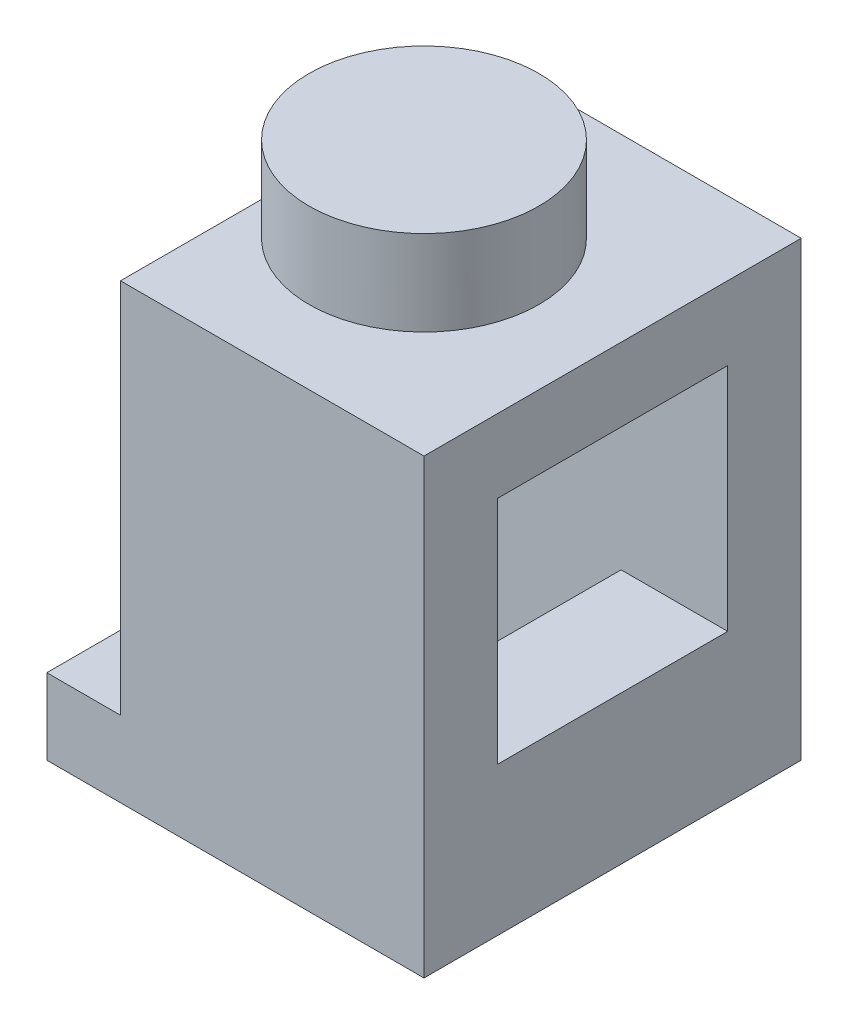
from build123d import *

# Parameters (mm, degrees)
SKETCH1_W      = 7.96
SKETCH1_H      = 7.96
EXTRUDE1_DEPTH = 9.54
SKETCH2_R      = 2.425
EXTRUDE2_DEPTH = 1.8
SHELL1_T       = -1.55
SKETCH3_W      = 4.86
SKETCH3_H      = 4.86
EXTRUDE3_DEPTH = 0.14
SKETCH5_W      = 1.555
SKETCH5_H      = 7.96
EXTRUDE5_DEPTH = 7.94
SKETCH7_W      = 0.7
SKETCH7_H      = 4.86
EXTRUDE6_DEPTH = 6.53
EXTRUDE7_REACH = 9.96
SKETCH4_W      = 4.86
SKETCH4_H      = 4.86
SKETCH8_R      = 2.425
EXTRUDE8_DEPTH = 1.555
SKETCH9_R      = 1.565
EXTRUDE9_DEPTH = 8.96


with BuildPart() as part:
    # Sketch1 → Extrude1 (new body)
    with BuildSketch(Plane(origin=(0, 0, 0), x_dir=(1, 0, 0), z_dir=(0, 1, 0))):
        Rectangle(SKETCH1_W, SKETCH1_H)
    extrude(amount=EXTRUDE1_DEPTH)

    # Sketch2 → Extrude2 (add)
    with BuildSketch(Plane(origin=(0, 9.54, 0), x_dir=(1, 0, 0), z_dir=(0, 1, 0))):
        Circle(SKETCH2_R)
    extrude(amount=EXTRUDE2_DEPTH)

    # Shell1
    shell1_openings = [part.faces().sort_by_distance(p)[0] for p in [
        (0, 0, 0),
    ]]
    offset(amount=SHELL1_T, openings=shell1_openings, kind=Kind.INTERSECTION)

    # Sketch3 → Extrude3 (cut)
    with BuildSketch(Plane.XZ.offset(-7.99)):
        Rectangle(SKETCH3_W, SKETCH3_H)
    extrude(amount=-EXTRUDE3_DEPTH, mode=Mode.SUBTRACT)

    # Sketch5 → Extrude5 (cut)
    with BuildSketch(Plane(origin=(0, 9.54, 0), x_dir=(1, 0, 0), z_dir=(0, 1, 0))):
        with Locations((-3.2025, 0)):
            Rectangle(SKETCH5_W, SKETCH5_H)
    extrude(amount=-EXTRUDE5_DEPTH, mode=Mode.SUBTRACT)

    # Sketch7 → Extrude6 (add)
    with BuildSketch(Plane.XZ.offset(-8.13)):
        with Locations((-2.075, 0)):
            Rectangle(SKETCH7_W, SKETCH7_H)
        with Locations((2.08, 0)):
            Rectangle(SKETCH7_W, SKETCH7_H)
    extrude(amount=EXTRUDE6_DEPTH)

    # Sketch4 → Extrude7 (cut, up to next)
    with BuildSketch(Plane(origin=(3.98, 0, 0), x_dir=(0, 0, -1), z_dir=(1, 0, 0)), mode=Mode.PRIVATE) as extrude7_sk1:
        with Locations((0, 5.56)):
            Rectangle(SKETCH4_W, SKETCH4_H)
    extrude7_tool1 = extrude(extrude7_sk1.sketch, amount=-EXTRUDE7_REACH, mode=Mode.PRIVATE) & part.part
    add(extrude7_tool1.solids().sort_by_distance((3.98, 5.56, 0))[0], mode=Mode.SUBTRACT)

    # Sketch8 → Extrude8 (add)
    with BuildSketch(Plane.ZY.offset(2.425)):
        with Locations((0, 5.56)):
            Circle(SKETCH8_R)
    extrude(amount=EXTRUDE8_DEPTH)

    # Sketch9 → Extrude9 (cut, through all)
    with BuildSketch(Plane.ZY.offset(3.98)):
        with Locations((0, 5.56)):
            Circle(SKETCH9_R)
    extrude(amount=-EXTRUDE9_DEPTH, mode=Mode.SUBTRACT)


solid = part.part
